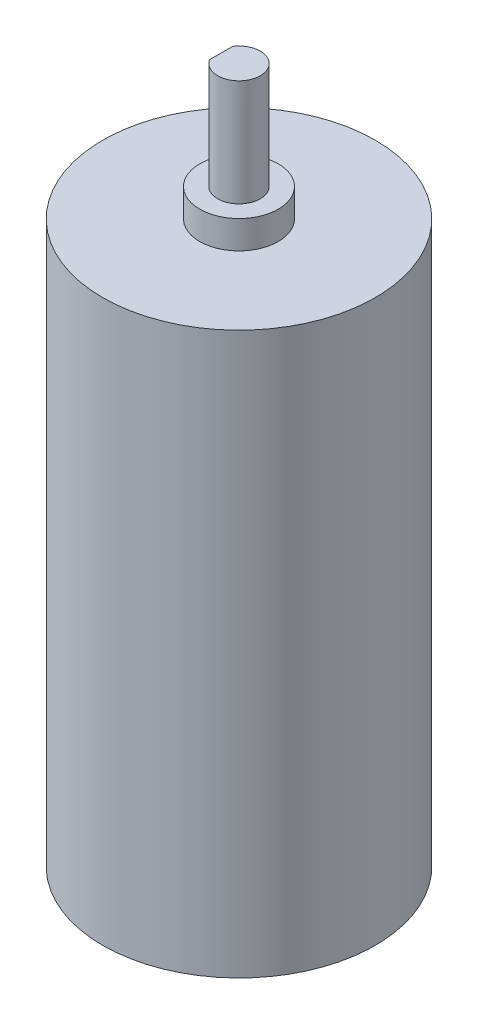
from build123d import *

# Parameters (mm, degrees)
SKETCH1_R           = 12.15
BOSS_EXTRUDE1_DEPTH = 50
SKETCH2_R           = 3.5
BOSS_EXTRUDE2_DEPTH = 2.5
BOSS_EXTRUDE3_DEPTH = 9.5
SKETCH4_R           = 1.901379474
BOSS_EXTRUDE4_DEPTH = 1.5


with BuildPart() as part:
    # Sketch1 → Boss-Extrude1 (new body)
    with BuildSketch(Plane(origin=(0, 0, 0), x_dir=(1, 0, 0), z_dir=(0, 1, 0))):
        Circle(SKETCH1_R)
    extrude(amount=BOSS_EXTRUDE1_DEPTH)

    # Sketch2 → Boss-Extrude2 (add)
    with BuildSketch(Plane(origin=(0, 50, 0), x_dir=(1, 0, 0), z_dir=(0, 1, 0))):
        Circle(SKETCH2_R)
    extrude(amount=BOSS_EXTRUDE2_DEPTH)

    # Sketch3 → Boss-Extrude3 (add)
    with BuildSketch(Plane(origin=(0, 52.5, 0), x_dir=(1, 0, 0), z_dir=(0, 1, 0))):
        with BuildLine():
            Line((-1.598620526, 1.029396092), (-1.598620526, -1.029396092))
            ThreePointArc((-1.598620526, -1.029396092), (1.901379474, 0), (-1.598620526, 1.029396092))
        make_face()
    extrude(amount=BOSS_EXTRUDE3_DEPTH)

    # Sketch4 → Boss-Extrude4 (add)
    with BuildSketch(Plane(origin=(0, 52.5, 0), x_dir=(1, 0, 0), z_dir=(0, 1, 0))):
        Circle(SKETCH4_R)
    extrude(amount=BOSS_EXTRUDE4_DEPTH)


solid = part.part
